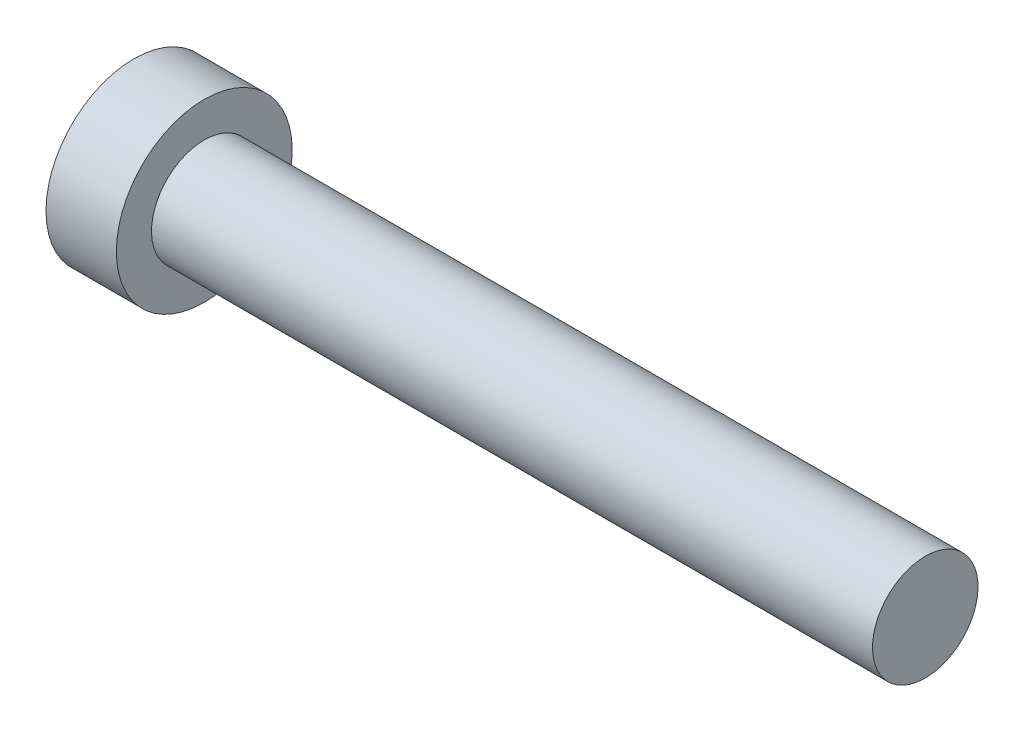
from build123d import *


with BuildPart() as part:
    # Esquisse1 → Révolution1 (revolve)
    with BuildSketch(Plane.XY):
        Polygon((0, 0), (0, 5), (4, 5), (4, 3), (45, 3), (45, 0), align=None)
    revolve(axis=Axis((45, 0, 0), (-1, 0, 0)))


solid = part.part
